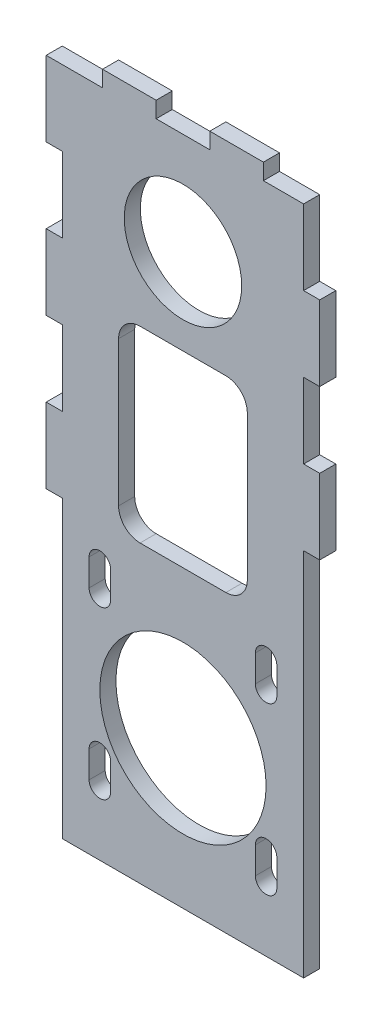
from build123d import *

# Parameters (mm, degrees)
SKETCH1_W           = 45
SKETCH1_H           = 70
BOSS_EXTRUDE1_DEPTH = 3
SKETCH2_R           = 10.95
SKETCH2_W           = 24
SKETCH2_H           = 35
CUT_EXTRUDE1_DEPTH  = 4
SKETCH4_W           = 10
SKETCH4_H           = 3
BOSS_EXTRUDE3_DEPTH = 3
SKETCH3_W           = 3
SKETCH3_H           = 14
BOSS_EXTRUDE2_DEPTH = 3
SKETCH5_W           = 45
SKETCH5_H           = 55
BOSS_EXTRUDE4_DEPTH = 3
FILLET1_R           = 4
SKETCH6_R           = 15.5
CUT_EXTRUDE2_DEPTH  = 10


with BuildPart() as part:
    # Sketch1 → Boss-Extrude1 (new body)
    with BuildSketch(Plane.XY):
        Rectangle(SKETCH1_W, SKETCH1_H)
    extrude(amount=BOSS_EXTRUDE1_DEPTH)

    # Sketch2 → Cut-Extrude1 (cut, through all)
    with BuildSketch(Plane.XY.offset(3)):
        with Locations((0, 16)):
            Circle(SKETCH2_R)
        with Locations((0, -17.5)):
            Rectangle(SKETCH2_W, SKETCH2_H)
    extrude(amount=-CUT_EXTRUDE1_DEPTH, mode=Mode.SUBTRACT)

    # Sketch4 → Boss-Extrude3 (add)
    with BuildSketch(Plane.XY.offset(3)):
        with Locations((-10, 36.5)):
            Rectangle(SKETCH4_W, SKETCH4_H)
        with Locations((10, 36.5)):
            Rectangle(SKETCH4_W, SKETCH4_H)
    extrude(amount=-BOSS_EXTRUDE3_DEPTH)

    # Sketch3 → Boss-Extrude2 (add)
    with BuildSketch(Plane(origin=(0, 0, 0), x_dir=(-1, 0, 0), z_dir=(0, 0, -1))):
        with Locations((24, 0)):
            Rectangle(SKETCH3_W, SKETCH3_H)
        with Locations((24, 28)):
            Rectangle(SKETCH3_W, SKETCH3_H)
        with Locations((24, -28)):
            Rectangle(SKETCH3_W, SKETCH3_H)
        with Locations((-24, 14)):
            Rectangle(SKETCH3_W, SKETCH3_H)
        with Locations((-24, -14)):
            Rectangle(SKETCH3_W, SKETCH3_H)
    extrude(amount=-BOSS_EXTRUDE2_DEPTH)

    # Sketch5 → Boss-Extrude4 (add)
    with BuildSketch(Plane.XY.offset(3)):
        with Locations((0, -62.5)):
            Rectangle(SKETCH5_W, SKETCH5_H)
    extrude(amount=-BOSS_EXTRUDE4_DEPTH)

    # Fillet1
    fillet1_edges = [part.edges().sort_by_distance(p)[0] for p in [
        (12, 0, 1.5),
        (12, -35, 1.5),
        (-12, -35, 1.5),
        (-12, 0, 1.5),
    ]]
    fillet(fillet1_edges, radius=FILLET1_R)

    # Sketch6 → Cut-Extrude2 (cut)
    with BuildSketch(Plane(origin=(0, 0, 0), x_dir=(-1, 0, 0), z_dir=(0, 0, -1))):
        with Locations((0, -62.5)):
            Circle(SKETCH6_R)
        with BuildLine():
            Line((13.5, -78), (13.5, -73))
            ThreePointArc((13.5, -73), (15.5, -71), (17.5, -73))
            Line((17.5, -73), (17.5, -78))
            ThreePointArc((17.5, -78), (15.5, -80), (13.5, -78))
        make_face()
        with BuildLine():
            Line((-17.5, -78), (-17.5, -73))
            ThreePointArc((-17.5, -73), (-15.5, -71), (-13.5, -73))
            Line((-13.5, -73), (-13.5, -78))
            ThreePointArc((-13.5, -78), (-15.5, -80), (-17.5, -78))
        make_face()
        with BuildLine():
            Line((-17.5, -47), (-17.5, -42))
            ThreePointArc((-17.5, -42), (-15.5, -40), (-13.5, -42))
            Line((-13.5, -42), (-13.5, -47))
            ThreePointArc((-13.5, -47), (-15.5, -49), (-17.5, -47))
        make_face()
        with BuildLine():
            Line((13.5, -47), (13.5, -42))
            ThreePointArc((13.5, -42), (15.5, -40), (17.5, -42))
            Line((17.5, -42), (17.5, -47))
            ThreePointArc((17.5, -47), (15.5, -49), (13.5, -47))
        make_face()
    extrude(amount=-CUT_EXTRUDE2_DEPTH, mode=Mode.SUBTRACT)


solid = part.part
